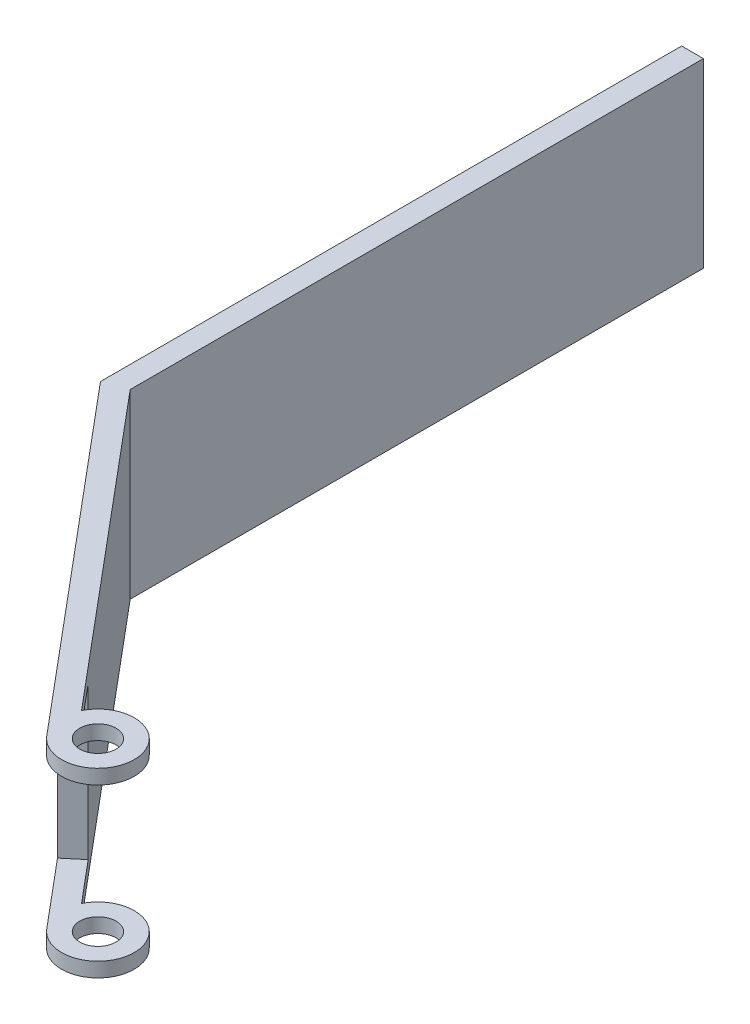
from build123d import *

# Parameters (mm, degrees)
ESQUISSE1_R      = 2.5
EXTRUSION1_DEPTH = 25
ESQUISSE2_W      = 30
ESQUISSE2_H      = 21
EXTRUSION2_DEPTH = 88.731584025


with BuildPart() as part:
    # Esquisse1 → Extrusion1 (new body)
    with BuildSketch(Plane(origin=(0, 0, 0), x_dir=(1, 0, 0), z_dir=(0, 1, 0))):
        with BuildLine():
            Line((0, 0), (-3, 0))
            Line((-3, 0), (-3, -80))
            Line((-3, -80), (35.567256581, -125.962666587))
            ThreePointArc((35.567256581, -125.962666587), (44.362418985, -122.157654154), (34.919767033, -120.523847112))
            Line((34.919767033, -120.523847112), (0, -78.908089297))
            Line((0, -78.908089297), (0, 0))
        make_face()
        with Locations((39.397478797, -122.748728539)):
            Circle(ESQUISSE1_R, mode=Mode.SUBTRACT)
    extrude(amount=EXTRUSION1_DEPTH)

    # Esquisse2 → Extrusion2 (cut, through all)
    with BuildSketch(Plane(origin=(-41.152782387, 0, 34.531284523), x_dir=(0.64278761, 0, 0.766044443), z_dir=(-0.766044443, 0, 0.64278761))):
        with Locations((122.35519262, 12.5)):
            Rectangle(ESQUISSE2_W, ESQUISSE2_H)
    extrude(amount=-EXTRUSION2_DEPTH, mode=Mode.SUBTRACT)


solid = part.part
